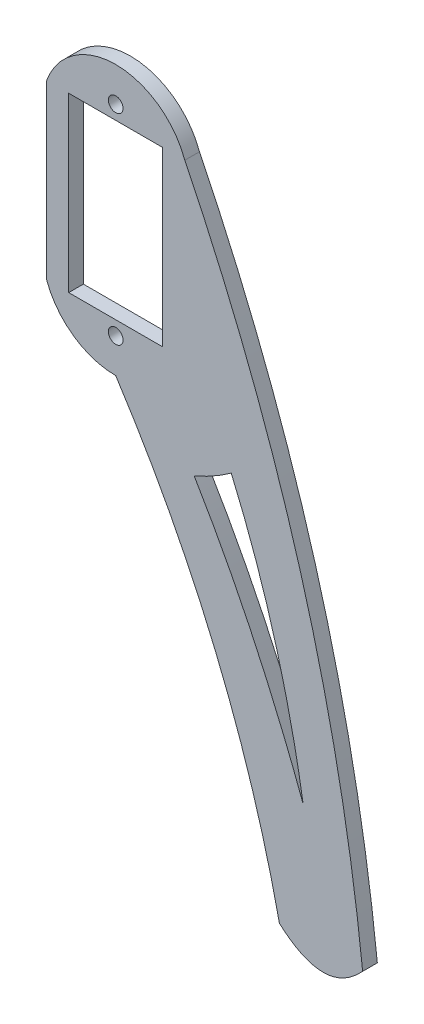
from build123d import *

# Parameters (mm, degrees)
SKETCH1_R           = 1
SKETCH1_W           = 12.8
SKETCH1_H           = 23.5
BOSS_EXTRUDE1_DEPTH = 2


with BuildPart() as part:
    # Sketch1 → Boss-Extrude1 (new body)
    with BuildSketch(Plane.XY):
        with BuildLine():
            Line((-9.4, 11.75), (-9.4, -11.75))
            ThreePointArc((-9.4, -11.75), (-5.739449267, -16.527194588), (0, -18.338255578))
            ThreePointArc((0, -18.338255578), (13.57537109, -44.028371556), (22.280776055, -71.75))
            add(Edge.make_bspline(
                [(33.607962355, -71.75), (28.503418884, -77.33913538), (22.280776055, -71.75)],
                knots=[0, 0, 0, 1, 1, 1], degree=2))
            ThreePointArc((33.607962355, -71.75), (25.161513792, -28.93962381), (9.4, 11.75))
            ThreePointArc((9.4, 11.75), (0, 18.338255578), (-9.4, 11.75))
        make_face()
        with Locations((0, -13.65)):
            Circle(SKETCH1_R, mode=Mode.SUBTRACT)
        Rectangle(SKETCH1_W, SKETCH1_H, mode=Mode.SUBTRACT)
        with Locations((0, 13.65)):
            Circle(SKETCH1_R, mode=Mode.SUBTRACT)
        with BuildLine():
            add(Edge.make_bspline(
                [(15.725665239, -21.969234099), (22.521602369, -37.712210356), (25.511369443, -56.077189315)],
                knots=[0, 0, 0, 1, 1, 1], degree=2))
            add(Edge.make_bspline(
                [(10.679903774, -24.816999203), (19.088197707, -38.847286621), (25.511369443, -56.077189315)],
                knots=[0, 0, 0, 1, 1, 1], degree=2))
            ThreePointArc((10.679903774, -24.816999203), (13.279343366, -23.528766092), (15.725665239, -21.969234099))
        make_face(mode=Mode.SUBTRACT)
    extrude(amount=BOSS_EXTRUDE1_DEPTH)


solid = part.part
